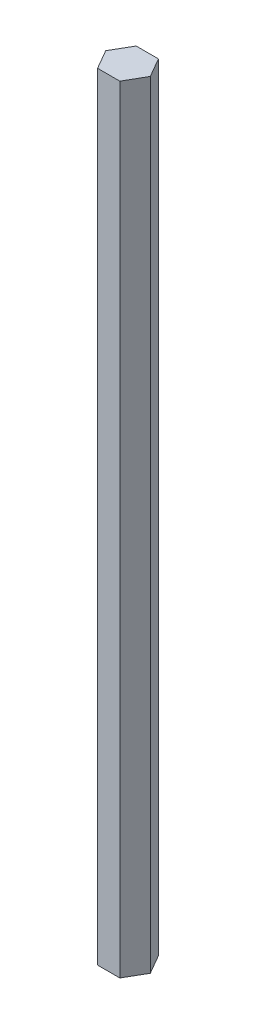
from build123d import *

# Parameters (mm, degrees)
BOSS_EXTRUDE1_DEPTH = 127.824992


with BuildPart() as part:
    # Sketch1 → Boss-Extrude1 (new body, symmetric)
    with BuildSketch(Plane(origin=(0, 0, 0), x_dir=(1, 0, 0), z_dir=(0, 1, 0))):
        Polygon((7.332348419, 0), (3.666174209, 6.35), (-3.666174209, 6.35), (-7.332348419, 0), (-3.666174209, -6.35), (3.666174209, -6.35), align=None)
    extrude(amount=BOSS_EXTRUDE1_DEPTH, both=True)


solid = part.part
